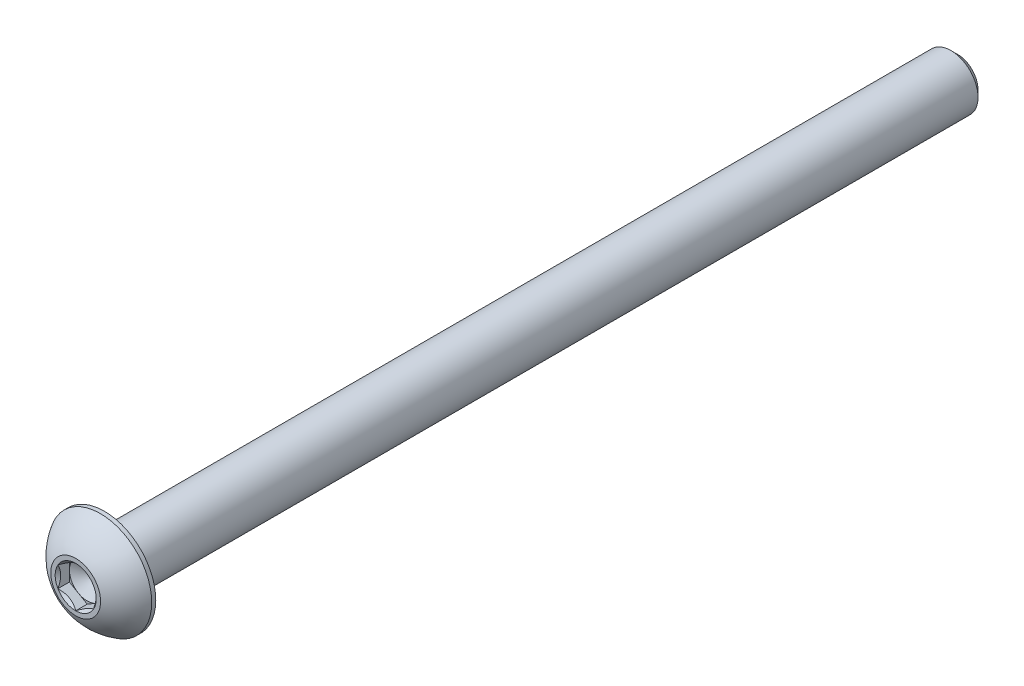
from build123d import *

# Parameters (mm, degrees)
CUT_EXTRUDE1_START = 38.35654
CUT_EXTRUDE1_DEPTH = 2.02616
SKETCH4_R          = 1.833087105
CUT_EXTRUDE2_DEPTH = 1.02616
CUT_EXTRUDE2_DRAFT = -45


with BuildPart() as part:
    # Sketch2 → Revolve1 (revolve)
    with BuildSketch(Plane(origin=(0, 0, 0), x_dir=(0, 0, -1), z_dir=(1, 0, 0))):
        with BuildLine():
            Line((-39.3827, 1.5875), (-39.3827, 2.2225))
            ThreePointArc((-39.3827, 2.2225), (-38.467752118, 3.57733025), (-37.180157143, 4.5847))
            Line((-37.180157143, 4.5847), (-36.8173, 4.5847))
            Line((-36.8173, 4.5847), (-36.8173, 2.413))
            Line((-36.8173, 2.413), (38.7873875, 2.413))
            Line((38.7873875, 2.413), (39.3827, 1.8176875))
            Line((39.3827, 1.8176875), (39.3827, 0))
            Line((39.3827, 0), (-37.439996448, 0))
            Line((-37.439996448, 0), (-38.35654, 1.5875))
            Line((-38.35654, 1.5875), (-39.3827, 1.5875))
        make_face()
    revolve(axis=Axis((0, 0, 39.3827), (0, 0, -1)))

    # Sketch3 → Cut-Extrude1 (cut, through all)
    with BuildSketch(Plane.XY.offset(CUT_EXTRUDE1_START)):
        Polygon((0, 1.833087105), (-1.5875, 0.916543552), (-1.5875, -0.916543552), (0, -1.833087105), (1.5875, -0.916543552), (1.5875, 0.916543552), align=None)
    extrude(amount=CUT_EXTRUDE1_DEPTH, mode=Mode.SUBTRACT)


with BuildPart() as cut_extrude2_tool:
    # Sketch4 → Cut-Extrude2 (with draft: the straight prism first)
    with BuildSketch(Plane.XY.offset(39.3827)):
        Circle(SKETCH4_R)
    extrude(amount=-CUT_EXTRUDE2_DEPTH)
    # Cut-Extrude2: the draft: its side faces are tilted about the plane it starts from
    cut_extrude2_sides = [cut_extrude2_tool.faces().sort_by_distance(p)[0] for p in [
        (-1.833087105, 0, 38.86962),
    ]]
    draft(cut_extrude2_sides, Plane.XY.offset(39.3827), CUT_EXTRUDE2_DRAFT)


with BuildPart() as part_1:
    add(part.part)

    # Cut-Extrude2: cut by cut_extrude2_tool
    add(cut_extrude2_tool.part, mode=Mode.SUBTRACT)


solid = part_1.part
